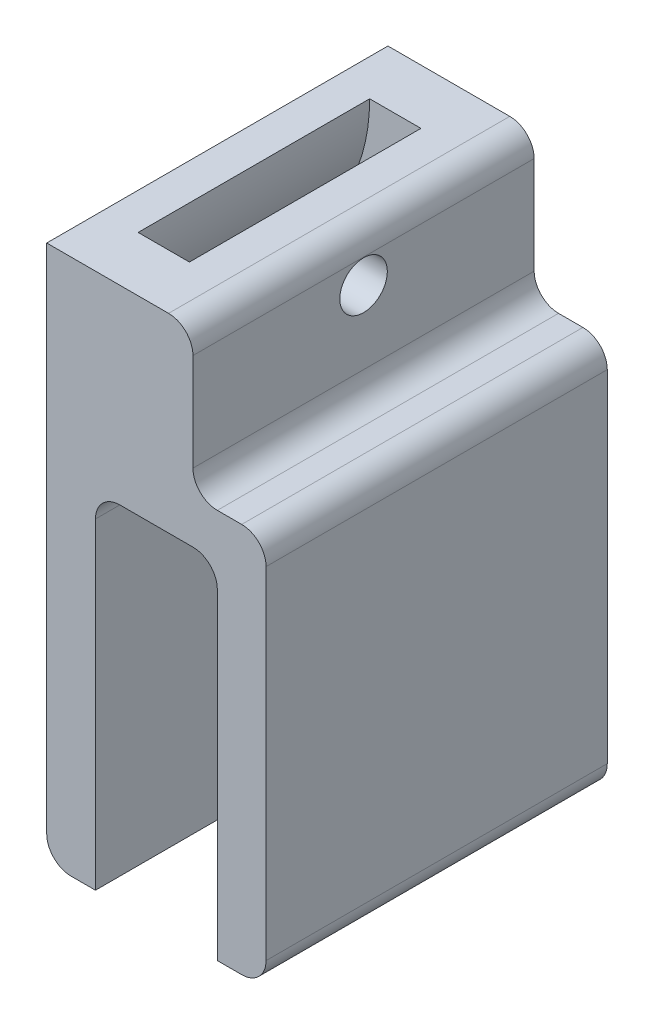
from build123d import *

# Parameters (mm, degrees)
BOSS_EXTRUDE3_DEPTH = 14
SKETCH5_W           = 9.5
SKETCH5_H           = 3
SKETCH9_R           = 0.975
CUT_EXTRUDE1_DEPTH  = 4.5
CUT_EXTRUDE3_DEPTH  = 1
FILLET2_R           = 4


with BuildPart() as part:
    # Sketch4 → Boss-Extrude3 (new body)
    with BuildSketch(Plane.XY):
        with BuildLine():
            Line((7, -16), (8, -16))
            ThreePointArc((8, -16), (8.707106781, -15.707106781), (9, -15))
            Line((9, -15), (9, -1))
            ThreePointArc((9, -1), (8.707106781, -0.292893219), (8, 0))
            Line((8, 0), (7, 0))
            ThreePointArc((7, 0), (6.292893219, 0.292893219), (6, 1))
            Line((6, 1), (6, 5))
            ThreePointArc((6, 5), (5.707106781, 5.707106781), (5, 6))
            Line((5, 6), (0, 6))
            Line((0, 6), (0, 0))
            Line((0, 0), (0, -15))
            ThreePointArc((0, -15), (0.292893219, -15.707106781), (1, -16))
            Line((1, -16), (2, -16))
            Line((2, -16), (2, -2.806818182))
            ThreePointArc((2, -2.806818182), (2.292893219, -2.099711401), (3, -1.806818182))
            Line((3, -1.806818182), (6, -1.806818182))
            ThreePointArc((6, -1.806818182), (6.707106781, -2.099711401), (7, -2.806818182))
            Line((7, -2.806818182), (7, -16))
        make_face()
    extrude(amount=BOSS_EXTRUDE3_DEPTH)

    # Cut-Sweep2: sweep along a path in Sketch8
    with BuildLine(Plane.XY.offset(14)) as cut_sweep2_path:
        CenterArc((-6, 6), 11, 0, 360)
    # Sketch5 → Cut-Sweep2 (sweep, cut)
    with BuildSketch(Plane.ZY):
        with Locations((7, 0)):
            Rectangle(SKETCH5_W, SKETCH5_H)
    sweep(path=cut_sweep2_path.line, mode=Mode.SUBTRACT)

    # Sketch9 → Cut-Extrude1 (cut)
    with BuildSketch(Plane(origin=(6, 0, 0), x_dir=(0, 0, -1), z_dir=(1, 0, 0))):
        with Locations((-7, 4)):
            Circle(SKETCH9_R)
    extrude(amount=-CUT_EXTRUDE1_DEPTH, mode=Mode.SUBTRACT)

    # Sketch11 → Cut-Extrude3 (cut)
    with BuildSketch(Plane.ZY):
        Polygon((2.25, -1.5), (2.25, 0), (11.75, 0), (11.75, -1.5), (11.75, -16), (2.25, -16), align=None)
    extrude(amount=-CUT_EXTRUDE3_DEPTH, mode=Mode.SUBTRACT)

    # Fillet2
    fillet2_edges = [part.edges().sort_by_distance(p)[0] for p in [
        (1, -0.576473219, 7),
    ]]
    fillet(fillet2_edges, radius=FILLET2_R)


solid = part.part
